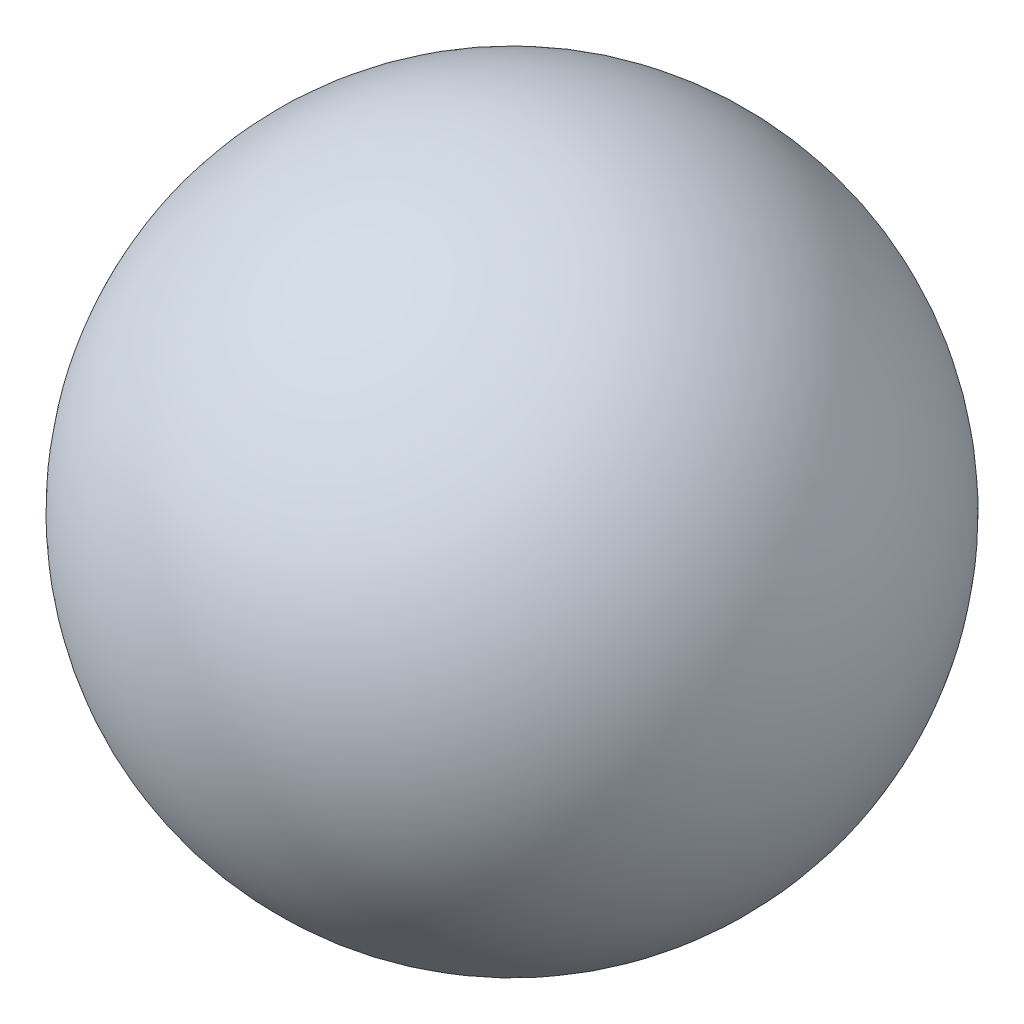
from build123d import *


with BuildPart() as part:
    # Sketch2 → Revolve1 (revolve)
    with BuildSketch(Plane(origin=(0, 0, 0), x_dir=(1, 0, 0), z_dir=(0, 1, 0))):
        with BuildLine():
            Line((-0.8, 0), (0.8, 0))
            ThreePointArc((0.8, 0), (0, 0.8), (-0.8, 0))
        make_face()
    revolve(axis=Axis((-0.8, 0, 0), (1, 0, 0)))


solid = part.part
